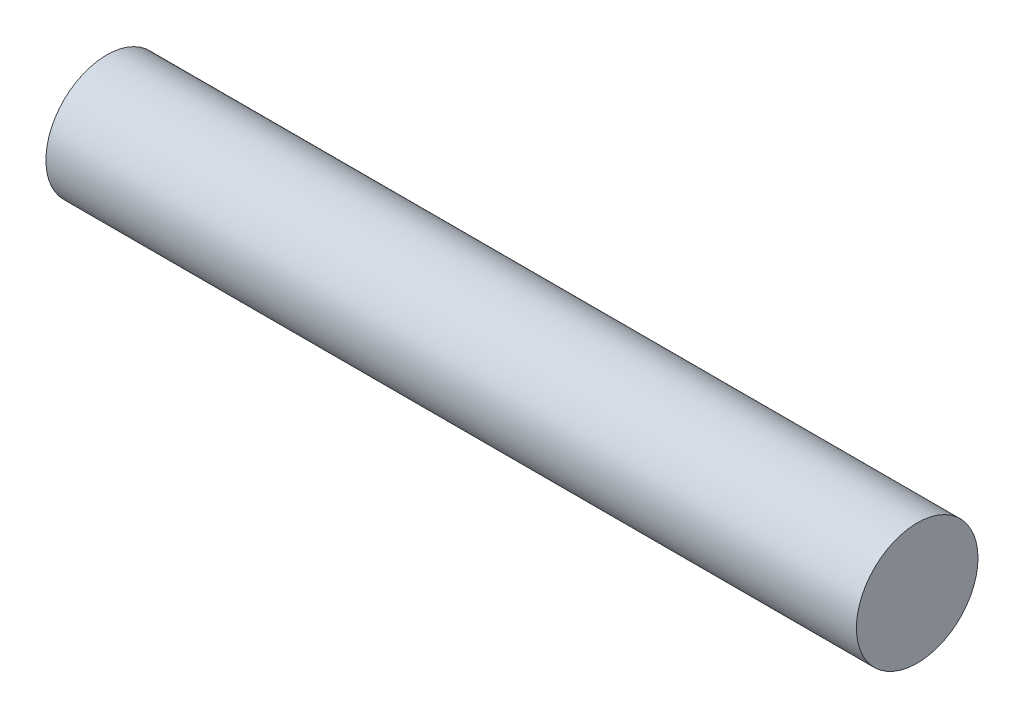
from build123d import *

# Parameters (mm, degrees)
SKETCH1_R           = 0.75
BOSS_EXTRUDE1_DEPTH = 10


with BuildPart() as part:
    # Sketch1 → Boss-Extrude1 (new body)
    with BuildSketch(Plane(origin=(0, 0, 0), x_dir=(0, 0, -1), z_dir=(1, 0, 0))):
        Circle(SKETCH1_R)
    extrude(amount=BOSS_EXTRUDE1_DEPTH)


solid = part.part
